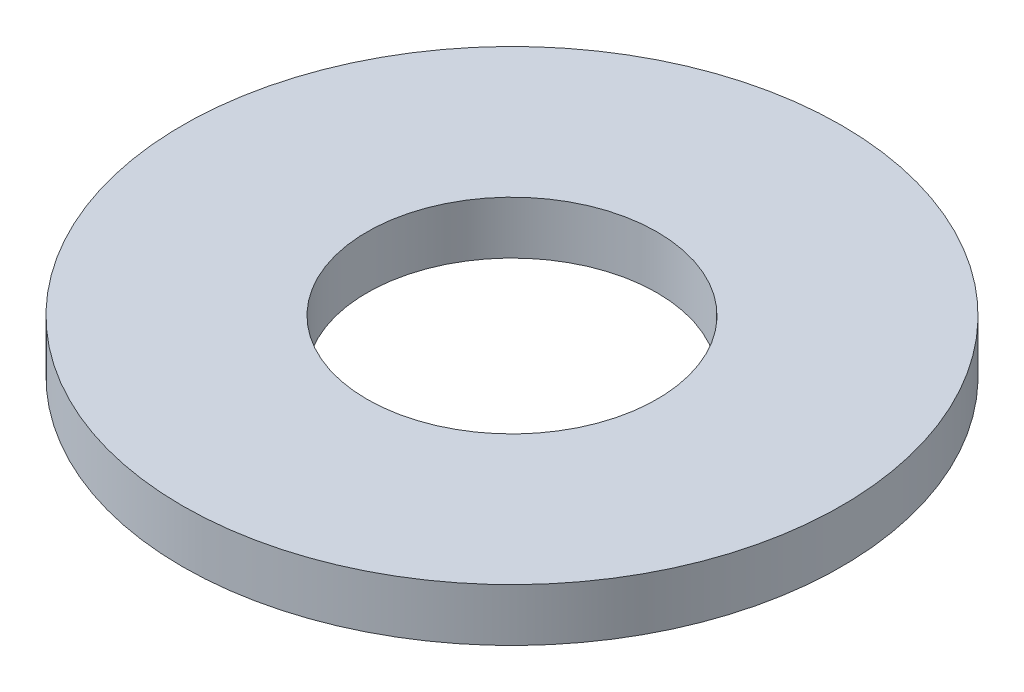
from build123d import *

# Parameters (mm, degrees)
SKETCH1_R           = 2.5
BOSS_EXTRUDE1_DEPTH = 0.4
SKETCH5_R           = 1.1
CUT_EXTRUDE1_DEPTH  = 1.4


with BuildPart() as part:
    # Sketch1 → Boss-Extrude1 (new body)
    with BuildSketch(Plane(origin=(0, 0, 0), x_dir=(1, 0, 0), z_dir=(0, 1, 0))):
        Circle(SKETCH1_R)
    extrude(amount=BOSS_EXTRUDE1_DEPTH)

    # Sketch5 → Cut-Extrude1 (cut, through all)
    with BuildSketch(Plane(origin=(0, 0.4, 0), x_dir=(-1, 0, 0), z_dir=(0, 1, 0))):
        Circle(SKETCH5_R)
    extrude(amount=-CUT_EXTRUDE1_DEPTH, mode=Mode.SUBTRACT)


solid = part.part
